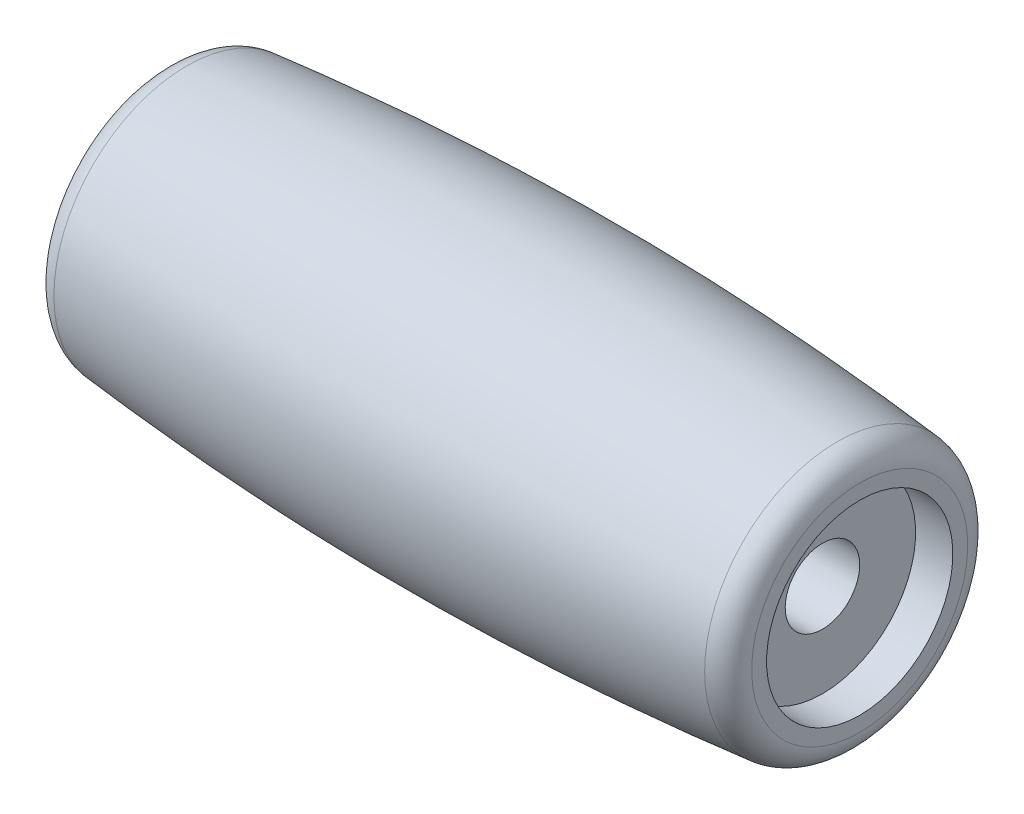
from build123d import *


with BuildPart() as part:
    # Sketch1 → Revolve1 (revolve)
    with BuildSketch(Plane.XY):
        with BuildLine():
            Line((-12.5, 1.5), (12.5, 1.5))
            Line((12.5, 1.5), (12.5, 3.75))
            Line((12.5, 3.75), (14, 3.75))
            Line((14, 3.75), (14, 4.348372713))
            ThreePointArc((14, 4.348372713), (13.741546609, 5.019274067), (13.099782746, 5.343381961))
            add(Edge.make_bspline(
                [(13.099782746, 5.343381961), (8.733258139, 5.781271175), (0.000693828, 6.218798404), (-8.734645795, 5.781132016), (-13.099782746, 5.343381961)],
                knots=[0.032151672, 0.032151672, 0.032151672, 0.032151672, 0.499994989, 0.967838306, 0.967838306, 0.967838306, 0.967838306], degree=3))
            ThreePointArc((-13.099782746, 5.343381961), (-13.741546609, 5.019274067), (-14, 4.348372713))
            Line((-14, 4.348372713), (-14, 3.75))
            Line((-14, 3.75), (-12.5, 3.75))
            Line((-12.5, 3.75), (-12.5, 1.5))
        make_face()
    revolve(axis=Axis((-75, 0, 0), (1, 0, 0)))


solid = part.part
